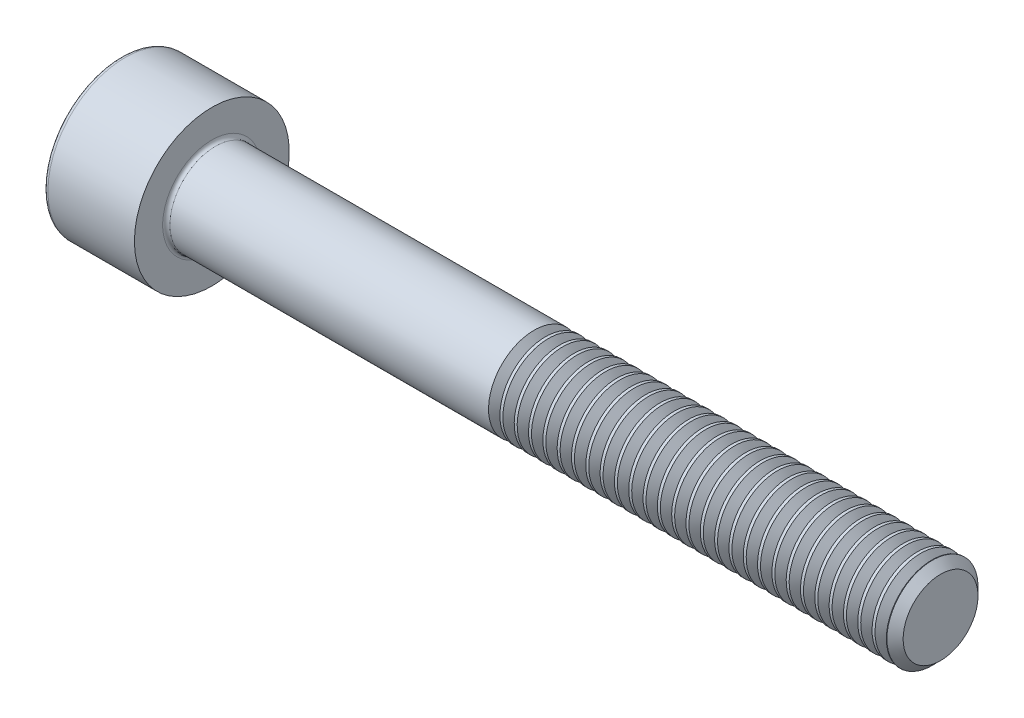
from build123d import *

# Parameters (mm, degrees)
FILLET1_R       = 0.2
FILLET2_R       = 0.25
HEX_2_DEPTH     = 2.5
THDSCHPAT_COUNT = 29
THDSCHPAT_PITCH = 0.785714286


with BuildPart() as part:
    # BodySke → Base-Revolve (revolve)
    with BuildSketch(Plane.XY):
        Polygon((0, 0), (0, 4.25), (5, 4.25), (5, 2.5), (44.555, 2.5), (45, 2.055), (45, 0), align=None)
    revolve(axis=Axis((-31.75, 0, 0), (1, 0, 0)))

    # Fillet1
    fillet1_edges = [part.edges().sort_by_distance(p)[0] for p in [
        (5, -2.5, 0),
    ]]
    fillet(fillet1_edges, radius=FILLET1_R)

    # Fillet2
    fillet2_edges = [part.edges().sort_by_distance(p)[0] for p in [
        (0, -4.25, 0),
    ]]
    fillet(fillet2_edges, radius=FILLET2_R)

    # Sketch2 → Hex-PreBroach (revolve, cut)
    with BuildSketch(Plane.XY):
        Polygon((0, 2.042), (2.5, 2.042), (3.67894925, 0), (0, 0), align=None)
    revolve(axis=Axis((0, 0, 0), (1, 0, 0)), mode=Mode.SUBTRACT)

    # Sketch3 → Hex 2 (cut)
    with BuildSketch(Plane(origin=(0, 0, 0), x_dir=(0, 0.5, 0.866025404), z_dir=(-1, 0, 0))):
        Polygon((1.17894925, 2.042), (-1.17894925, 2.042), (-2.357898499, 0), (-1.17894925, -2.042), (1.17894925, -2.042), (2.357898499, 0), align=None)
    extrude(amount=-HEX_2_DEPTH, mode=Mode.SUBTRACT)

    # ThdSchSke → ThreadSchematic (revolve, cut)
    with BuildSketch(Plane.XY):
        Polygon((23, -2.055), (22.688407645, -2.5), (22.688407645, -3.125), (23.311592355, -3.125), (23.311592355, -2.5), align=None)
    threadschematic = revolve(axis=Axis((-3.175, 0, 0), (1, 0, 0)), mode=Mode.SUBTRACT)

    # ThdSchPat: ThreadSchematic ×29
    with Locations(*[(i * THDSCHPAT_PITCH, 0, 0) for i in range(1, THDSCHPAT_COUNT)]):
        add(threadschematic, mode=Mode.SUBTRACT)


solid = part.part
